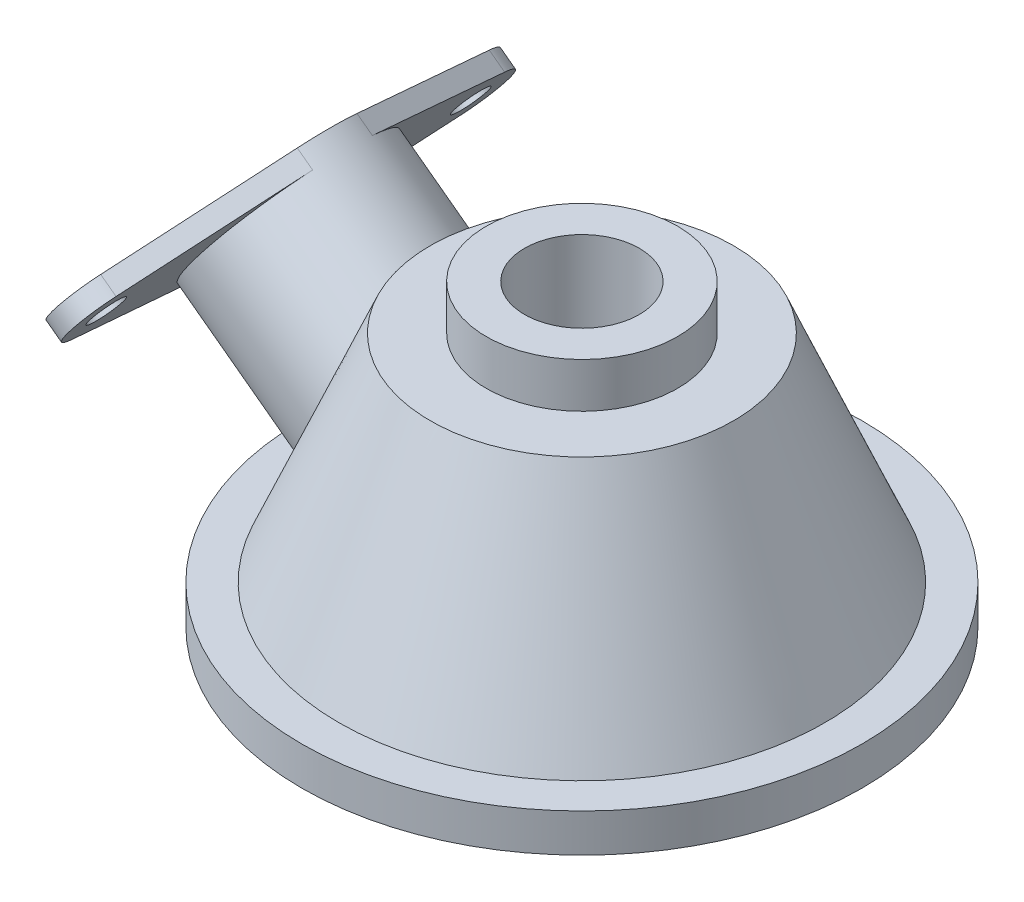
from build123d import *

# Parameters (mm, degrees)
SKETCH_4_R               = 4.59762215
EXTRUDE_1_DEPTH          = 5
EXTRUDE_1_2_DEPTH        = 5
EXTRUDE_2_REACH          = 182.584
SKETCH_4_3_R             = 25
SKETCH_4_3_R_2           = 20
CUT_EXTRUDE_1_DEPTH      = 181.584399592
CUT_EXTRUDE_1_DEPTH_BACK = 181.584399592
SKETCH_4_4_R             = 20


with BuildPart() as part:
    # 草图1 → 旋转1 (revolve)
    with BuildSketch(Plane.XY):
        Polygon((-15, 78.091052065), (-25, 78.091052065), (-25, 66.368643655), (-39.624031204, 66.368643655), (-63.50324307, 10), (-73.171930675, 10), (-73.171930675, 0), (-56.879211865, 0), (-33, 56.368643655), (-15, 56.368643655), align=None)
    revolve(axis=Axis((0, 0, 0), (0, 1, 0)))

    # 草图4<3> → 凸台-拉伸2 (add, up to next)
    with BuildSketch(Plane(origin=(-80.705417736, 59.819357933, 0), x_dir=(0, 0, 1), z_dir=(-0.8033782926562896, 0.5954689907028451, 0)), mode=Mode.PRIVATE) as extrude_2_sk1:
        Circle(SKETCH_4_3_R)
        Circle(SKETCH_4_3_R_2, mode=Mode.SUBTRACT)
    extrude_2_tool1 = extrude(extrude_2_sk1.sketch, amount=-EXTRUDE_2_REACH, mode=Mode.PRIVATE) - part.part
    add(extrude_2_tool1.solids().sort_by_distance((-80.705418, 59.819358, -24.292893))[0])

    # 草图4<4> → 切除-拉伸1 (cut, two sides: drawn at the far end of the back side and taken through both)
    with BuildSketch(Plane(origin=(-80.705417736, 59.819357933, 0), x_dir=(0, 0, 1), z_dir=(-0.8033782926562896, 0.5954689907028451, 0)).offset(-CUT_EXTRUDE_1_DEPTH_BACK)):
        Circle(SKETCH_4_4_R)
    extrude(amount=CUT_EXTRUDE_1_DEPTH + CUT_EXTRUDE_1_DEPTH_BACK, mode=Mode.SUBTRACT)


with BuildPart() as body_2:
    # 草图4 → 凸台-拉伸1 (new body)
    with BuildSketch(Plane(origin=(-80.705417736, 59.819357933, 0), x_dir=(0, 0, 1), z_dir=(-0.8033782926562896, 0.5954689907028451, 0))):
        with BuildLine():
            ThreePointArc((-12.160297615, -21.843240646), (-24.886535213, 2.379152178), (-7.801433677, 23.751581686))
            Line((-7.801433677, 23.751581686), (-50.758201751, 9.642021256))
            ThreePointArc((-50.758201751, 9.642021256), (-57.699738806, 0.143582546), (-50.92588329, -9.475157291))
            Line((-50.92588329, -9.475157291), (-12.160297615, -21.843240646))
        make_face()
        with Locations((-47.609278287, 0.055076602)):
            Circle(SKETCH_4_R, mode=Mode.SUBTRACT)
    extrude(amount=-EXTRUDE_1_DEPTH)


with BuildPart() as body_3:
    # 草图4 → Extrude 1 2 (new body)
    with BuildSketch(Plane(origin=(-80.705417736, 59.819357933, 0), x_dir=(0, 0, 1), z_dir=(-0.8033782926562896, 0.5954689907028451, 0))):
        with BuildLine():
            Line((50.758201751, 9.642021256), (7.801433677, 23.751581686))
            ThreePointArc((7.801433677, 23.751581686), (24.886535213, 2.379152178), (12.160297615, -21.843240646))
            Line((12.160297615, -21.843240646), (50.92588329, -9.475157291))
            ThreePointArc((50.92588329, -9.475157291), (57.699738806, 0.143582546), (50.758201751, 9.642021256))
        make_face()
        with Locations((47.609278287, 0.055076602)):
            Circle(SKETCH_4_R, mode=Mode.SUBTRACT)
    extrude(amount=-EXTRUDE_1_2_DEPTH)


solid = Compound([part.part, body_2.part, body_3.part])
